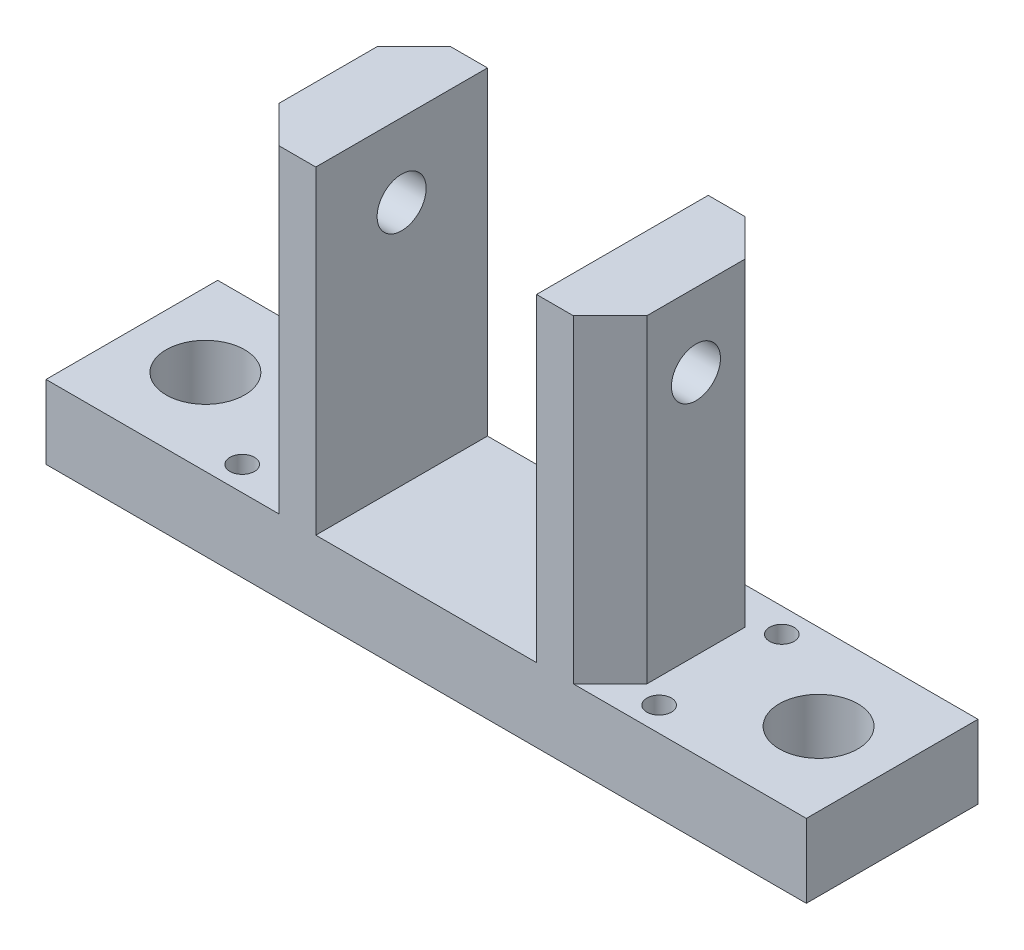
from build123d import *

# Parameters (mm, degrees)
EXTRUSION1_DEPTH        = 3.5
ESQUISSE2_R             = 1.6
ESQUISSE2_R_2           = 0.5
ENL_V_MAT_EXTRU_1_DEPTH = 4
ESQUISSE3_R             = 1
ENL_V_MAT_EXTRU_2_DEPTH = 24
CHANFREIN1_SIZE         = 1.5


with BuildPart() as part:
    # Esquisse1 → Extrusion1 (new body, symmetric)
    with BuildSketch(Plane.XY):
        Polygon((0, 0), (-31, 0), (-31, 3), (-23, 3), (-23, 16), (-20, 16), (-20, 3), (-11, 3), (-11, 16), (-8, 16), (-8, 3), (0, 3), align=None)
    extrude(amount=EXTRUSION1_DEPTH, both=True)

    # Esquisse2 → Enlèv. mat.-Extru.1 (cut, through all)
    with BuildSketch(Plane(origin=(0, 3, 0), x_dir=(-1, 0, 0), z_dir=(0, 1, 0))):
        with Locations(Location((28, 0, 0), (0, 0, 90))):  # turned: the seam where the file's is
            Circle(ESQUISSE2_R)
        with Locations(Location((3, 0, 0), (0, 0, 90))):  # turned: the seam where the file's is
            Circle(ESQUISSE2_R)
        with Locations(Location((24, -2.5, 0), (0, 0, 90))):  # turned: the seam where the file's is
            Circle(ESQUISSE2_R_2)
        with Locations(Location((24, 2.5, 0), (0, 0, 90))):  # turned: the seam where the file's is
            Circle(ESQUISSE2_R_2)
        with Locations(Location((7, 2.5, 0), (0, 0, 90))):  # turned: the seam where the file's is
            Circle(ESQUISSE2_R_2)
        with Locations(Location((7, -2.5, 0), (0, 0, 90))):  # turned: the seam where the file's is
            Circle(ESQUISSE2_R_2)
    extrude(amount=-ENL_V_MAT_EXTRU_1_DEPTH, mode=Mode.SUBTRACT)

    # Esquisse3 → Enlèv. mat.-Extru.2 (cut, through all)
    with BuildSketch(Plane.ZY.offset(23)):
        with Locations((0, 13)):
            Circle(ESQUISSE3_R)
    extrude(amount=-ENL_V_MAT_EXTRU_2_DEPTH, mode=Mode.SUBTRACT)

    # Chanfrein1
    chanfrein1_edges = [part.edges().sort_by_distance(p)[0] for p in [
        (-8, 9.5, 3.5),
        (-23, 9.5, -3.5),
        (-8, 9.5, -3.5),
        (-23, 9.5, 3.5),
    ]]
    chamfer(chanfrein1_edges, length=CHANFREIN1_SIZE)


solid = part.part
